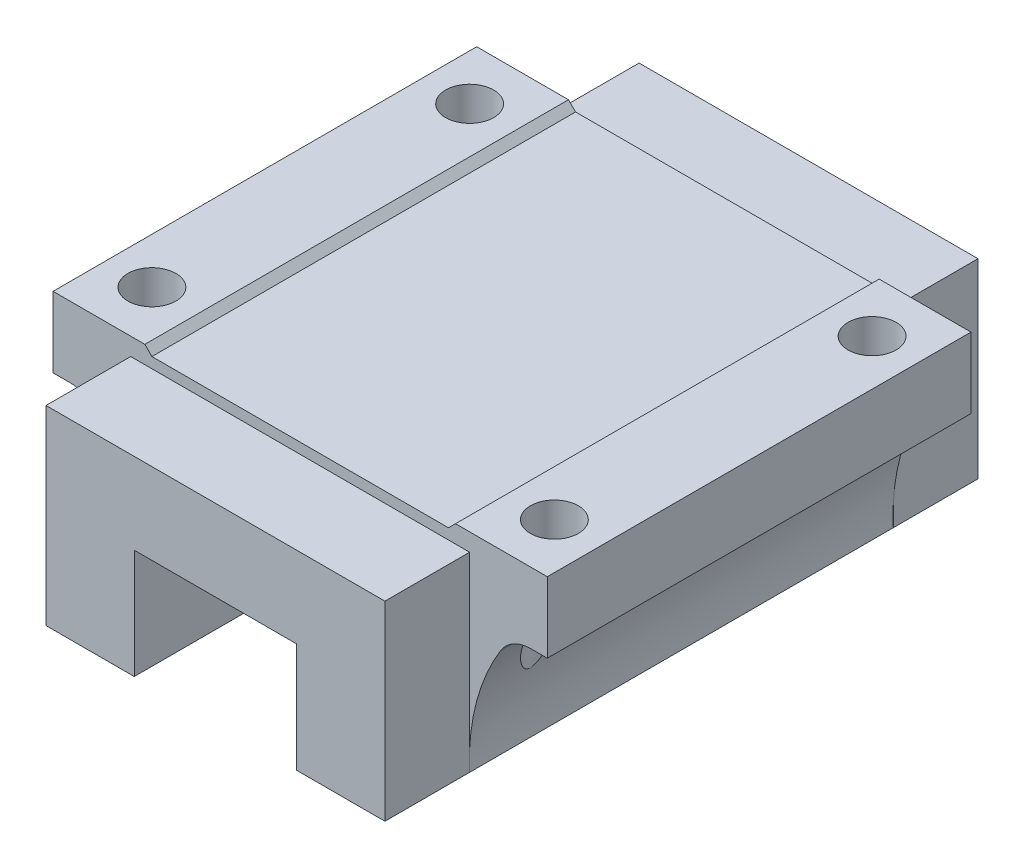
from build123d import *

# Parameters (mm, degrees)
EXTRUDE_1_DEPTH    = 30
HOLE_WIZARD_M8_1_D = 6.8
EXTRUDE_2_DEPTH    = 12


with BuildPart() as part:
    # 草图1 → 凸台-拉伸1 (new body, symmetric)
    with BuildSketch(Plane.XY):
        with BuildLine():
            Line((-21, 0), (21, 0))
            Line((21, 0), (22, 1))
            Line((22, 1), (35, 1))
            Line((35, 1), (35, -9))
            Line((35, -9), (32.639225352, -9))
            ThreePointArc((32.639225352, -9), (30.19452262, -9.638414445), (28.374113304, -11.390628579))
            ThreePointArc((28.374113304, -11.390628579), (24.899602423, -19.616168903), (24, -28.5))
            Line((24, -28.5), (11.5, -28.5))
            Line((11.5, -28.5), (11.5, -13))
            Line((11.5, -13), (-11.5, -13))
            Line((-11.5, -13), (-11.5, -28.5))
            Line((-11.5, -28.5), (-24, -28.5))
            ThreePointArc((-24, -28.5), (-24.899602423, -19.616168903), (-28.374113304, -11.390628579))
            ThreePointArc((-28.374113304, -11.390628579), (-30.19452262, -9.638414445), (-32.639225352, -9))
            Line((-32.639225352, -9), (-35, -9))
            Line((-35, -9), (-35, 1))
            Line((-35, 1), (-22, 1))
            Line((-22, 1), (-21, 0))
        make_face()
    extrude(amount=EXTRUDE_1_DEPTH, both=True)

    # M8 螺纹孔1 (through all)
    with Locations(Plane(origin=(0, 1, 0), x_dir=(1, 0, 0), z_dir=(0, 1, 0))):
        with Locations((-28.5, 22.5), (28.5, 22.5), (28.5, -22.5), (-28.5, -22.5)):
            Hole(HOLE_WIZARD_M8_1_D / 2)

    # 草图4 → 凸台-拉伸2 (add)
    with BuildSketch(Plane.XY.offset(30)):
        Polygon((-11.5, -28.5), (-11.5, -13), (11.5, -13), (11.5, -28.5), (24, -28.5), (24, -1.5), (-24, -1.5), (-24, -28.5), align=None)
    extrude_2 = extrude(amount=EXTRUDE_2_DEPTH)

    # 镜向1: 凸台-拉伸2 across plane
    add(extrude_2.mirror(Plane.XY))


solid = part.part
